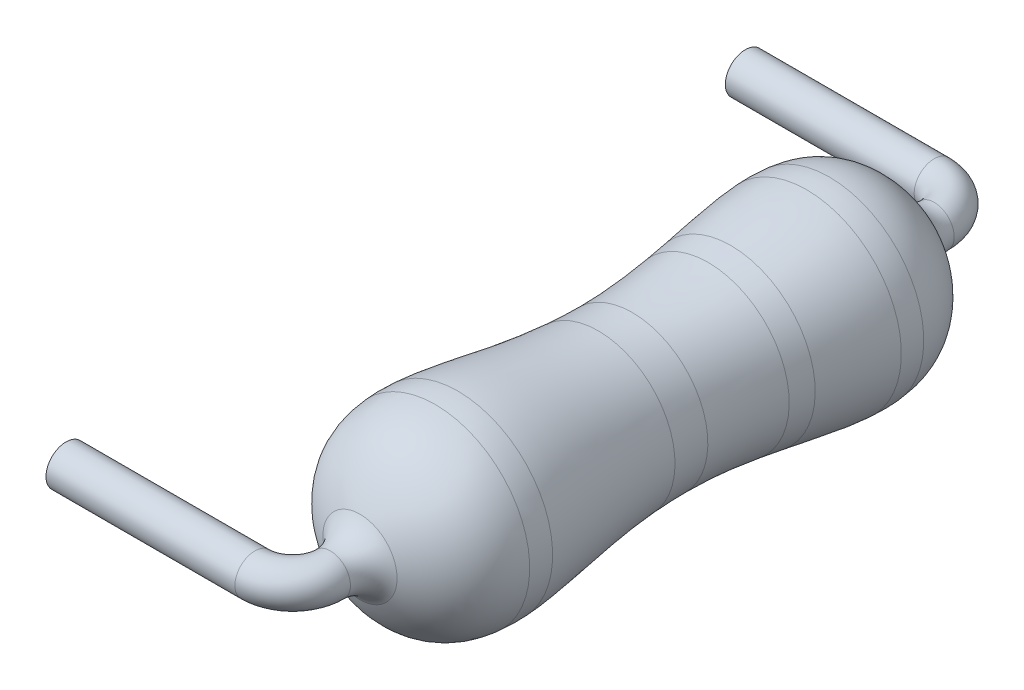
from build123d import *

# Parameters (mm, degrees)
SKETCH2_W = 7
SKETCH2_H = 0.265
SKETCH7_R = 0.265


with BuildPart() as part:
    # Sketch2 → Revolve1 (revolve)
    with BuildSketch(Plane(origin=(0, 0, 0), x_dir=(0, 0, -1), z_dir=(1, 0, 0)), mode=Mode.PRIVATE) as revolve1_sk:
        with Locations((0, 0.1325)):
            Rectangle(SKETCH2_W, SKETCH2_H)
    revolve(revolve1_sk.sketch.rotate(Axis((0, 0, 3.5), (0, 0, -1)), 90), axis=Axis((0, 0, 3.5), (0, 0, -1)))



with BuildPart() as body_2:
    # Sketch3 → Revolve2 (revolve)
    with BuildSketch(Plane(origin=(0, 0, 0), x_dir=(0, 0, -1), z_dir=(1, 0, 0))):
        with BuildLine():
            Line((-3.698125, 0.265), (3.698125, 0.265))
            add(Edge.make_bspline(
                [(-3.698125, 0.265), (-2.608304325, 3.259257695), (0, -1.767343593), (2.608304325, 3.259257695), (3.698125, 0.265)],
                knots=[0, 0, 0, 0, 0, 1, 1, 1, 1, 1], degree=4))
        make_face()
    revolve(axis=Axis((0, 0, -3.4), (0, 0, 1)))

    # Sketch4 → Revolve3 (revolve)
    with BuildSketch(Plane(origin=(0, 0, 0), x_dir=(0, 0, -1), z_dir=(1, 0, 0)), mode=Mode.PRIVATE) as revolve3_sk:
        with BuildLine():
            Line((-3.99625, 0.265), (3.99625, 0.265))
            ThreePointArc((3.99625, 0.265), (3.770360507, 0.325526907), (3.604997921, 0.490889493))
            Line((3.604997921, 0.490889493), (-3.604997921, 0.490889493))
            ThreePointArc((-3.604997921, 0.490889493), (-3.770360507, 0.325526907), (-3.99625, 0.265))
        make_face()
    revolve(revolve3_sk.sketch.rotate(Axis((0, 0, 3.99625), (0, 0, -1)), 90), axis=Axis((0, 0, 3.99625), (0, 0, -1)))


with BuildPart() as part_1:
    add(part.part)

    add(body_2.part)  # Sweep1 merges body 2
    # Sweep1: sweep along a path in Sketch6
    with BuildLine(Plane(origin=(0, 0, 0), x_dir=(1, 0, 0), z_dir=(0, 1, 0))) as sweep1_path:
        Line((-3, -4.49625), (-0.5, -4.49625))
        ThreePointArc((-0.5, -4.49625), (-0.146446609, -4.349803391), (0, -3.99625))
        Line((0, -3.99625), (0, 3.99625))
        ThreePointArc((0, 3.99625), (-0.146446609, 4.349803391), (-0.5, 4.49625))
        Line((-0.5, 4.49625), (-3, 4.49625))
    # Sketch7 → Sweep1 (sweep)
    with BuildSketch(Plane.XY):
        Circle(SKETCH7_R)
    sweep(path=sweep1_path.line)


solid = part_1.part
